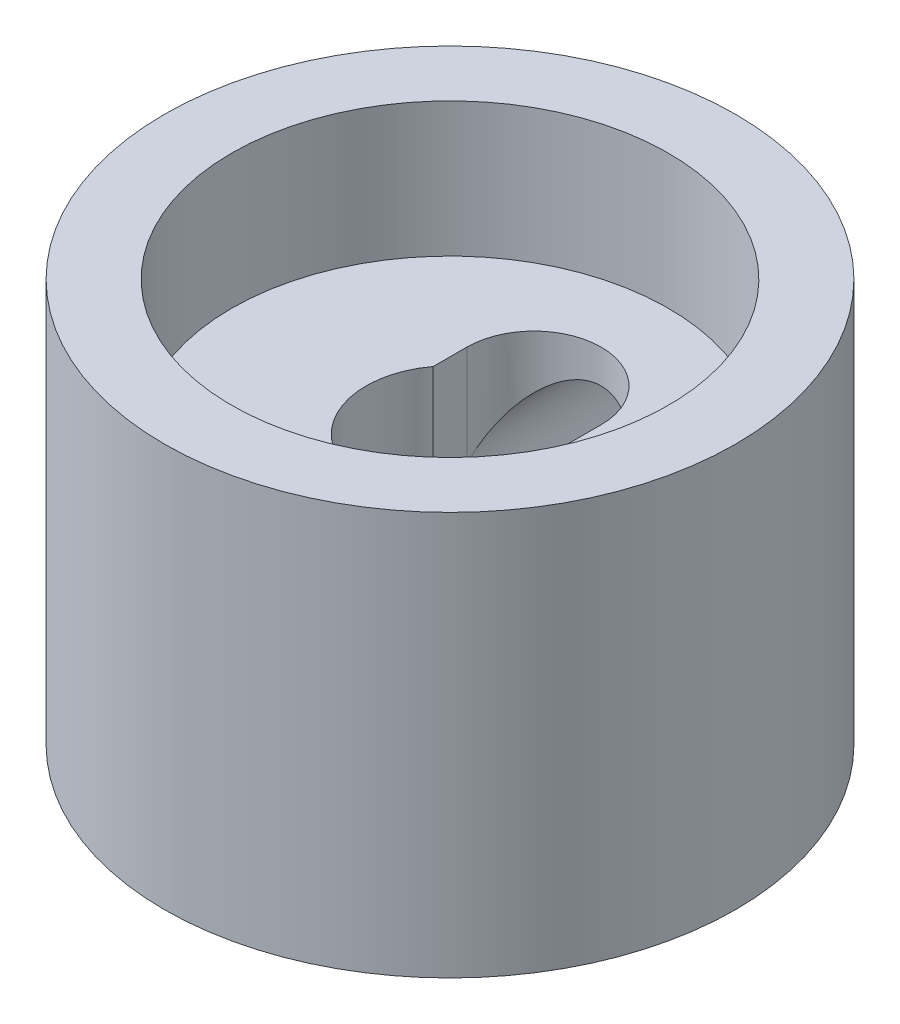
from build123d import *
from build123d.topology import SkipClean

# Parameters (mm, degrees)
SKETCH3_R          = 12.7
CUT_EXTRUDE1_DEPTH = 48.768
CUT_EXTRUDE2_DEPTH = 19.05


with BuildPart() as part:
    # Sketch1 → Revolve1 (revolve)
    with BuildSketch(Plane.XY, mode=Mode.PRIVATE) as revolve1_sk:
        Polygon((0, 0), (12.7, 0), (12.7, 3.175), (53.975, 3.175), (53.975, 79.375), (41.275, 79.375), (41.275, 53.975), (15.875, 53.975), (15.875, 22.225), (0, 22.225), align=None)
    revolve(revolve1_sk.sketch.rotate(Axis((0, 22.225, 0), (0, -1, 0)), 180), axis=Axis((0, 22.225, 0), (0, -1, 0)))

    # Sketch3 → Cut-Extrude1 (cut)
    with BuildSketch(Plane(origin=(0, 0, -53.975), x_dir=(-1, 0, 0), z_dir=(0, 0, -1))):
        with Locations((0, 34.925)):
            Circle(SKETCH3_R)
    extrude(amount=-CUT_EXTRUDE1_DEPTH, mode=Mode.SUBTRACT)

    # Sketch4 → Cut-Extrude2 (cut)
    with SkipClean():  # the faces are left unmerged after this step: merging them gives an invalid solid
        with BuildSketch(Plane(origin=(0, 53.975, 0), x_dir=(1, 0, 0), z_dir=(0, 1, 0))):
            with BuildLine():
                Line((-12.7, 15.875), (-12.7, 0))
                Line((-12.7, 0), (12.7, 0))
                Line((12.7, 0), (12.7, 15.875))
                ThreePointArc((12.7, 15.875), (0, 28.575), (-12.7, 15.875))
            make_face()
        extrude(amount=-CUT_EXTRUDE2_DEPTH, mode=Mode.SUBTRACT)


solid = part.part
